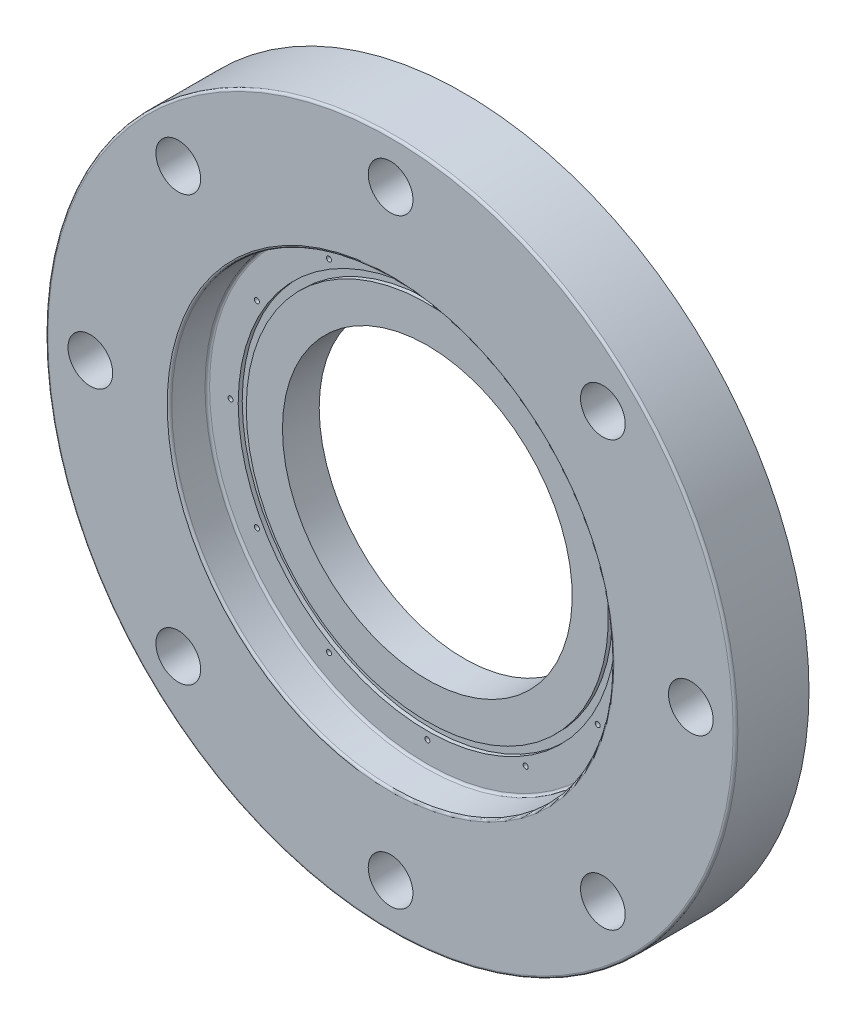
from build123d import *

# Parameters (mm, degrees)
SKETCH1_R          = 171.45
EXTRUDE1_DEPTH     = 36.5125
SKETCH2_R          = 11.1125
EXTRUDE2_DEPTH     = 37.5125
CIRPATTERN1_COUNT  = 8
FILLET1_R          = 1.154545455
SKETCH4_R          = 72
CUT_EXTRUDE1_DEPTH = 120
CIRPATTERN2_COUNT  = 12
SKETCH5_R          = 94
SKETCH5_R_2        = 90
CUT_EXTRUDE2_DEPTH = 2


with BuildPart() as part:
    # Sketch1 → Extrude1 (new body)
    with BuildSketch(Plane.XY):
        Circle(SKETCH1_R)
    extrude(amount=EXTRUDE1_DEPTH)

    # Sketch2 → Extrude2 (cut, through all)
    with BuildSketch(Plane.XY.offset(36.5125)):
        with Locations((0, 149.225)):
            Circle(SKETCH2_R)
    extrude2 = extrude(amount=-EXTRUDE2_DEPTH, mode=Mode.SUBTRACT)

    # CirPattern1: Extrude2 ×8 about axis
    cirpattern1_axis = Axis((0, 0, 0), (0, 0, 1))
    for i in range(1, CIRPATTERN1_COUNT):
        add(extrude2.rotate(cirpattern1_axis, i * 360 / CIRPATTERN1_COUNT), mode=Mode.SUBTRACT)

    # Sketch3 → Cut-Revolve1 (revolve, cut)
    with BuildSketch(Plane(origin=(0, 0, 0), x_dir=(0, 0, -1), z_dir=(1, 0, 0))):
        Polygon((-36.5125, 109.9185), (-18.25625, 109.347), (-18.25625, 0), (-36.5125, 0), align=None)
    revolve(axis=Axis((0, 0, 18.25625), (0, 0, 1)), mode=Mode.SUBTRACT)

    # Fillet1
    fillet1_edges = [part.edges().sort_by_distance(p)[0] for p in [
        (0, -109.347, 18.25625),
        (0, -109.9185, 36.5125),
        (-171.45, 0, 36.5125),
    ]]
    fillet(fillet1_edges, radius=FILLET1_R)

    # Sketch4 → Cut-Extrude1 (cut)
    with BuildSketch(Plane(origin=(0, 0, 0), x_dir=(-1, 0, 0), z_dir=(0, 0, -1))):
        Circle(SKETCH4_R)
    extrude(amount=-CUT_EXTRUDE1_DEPTH, mode=Mode.SUBTRACT)

    # Sketch8 → M3x0.5 Tapped Hole1 (revolve, cut)
    with BuildSketch(Plane(origin=(0, 97.79, 18.25625), x_dir=(0, -1, 0), z_dir=(1, 0, 0))):
        Polygon((0, 0), (0, 12.751075774), (1.25, 12), (1.25, 0), align=None)
    m3x0_5_tapped_hole1 = revolve(axis=Axis((0, 97.79, 24.60625), (0, 0, -1)), mode=Mode.SUBTRACT)

    # CirPattern2: M3x0.5 Tapped Hole1 ×12 about axis
    cirpattern2_axis = Axis((0, 0, 0), (0, 0, 1))
    for i in range(1, CIRPATTERN2_COUNT):
        add(m3x0_5_tapped_hole1.rotate(cirpattern2_axis, i * 360 / CIRPATTERN2_COUNT), mode=Mode.SUBTRACT)

    # Sketch5 → Cut-Extrude2 (cut)
    with BuildSketch(Plane(origin=(0, 0, 18.25625), x_dir=(-1, 0, 0), z_dir=(0, 0, -1))):
        Circle(SKETCH5_R)
        Circle(SKETCH5_R_2, mode=Mode.SUBTRACT)
    extrude(amount=CUT_EXTRUDE2_DEPTH, mode=Mode.SUBTRACT)


solid = part.part
